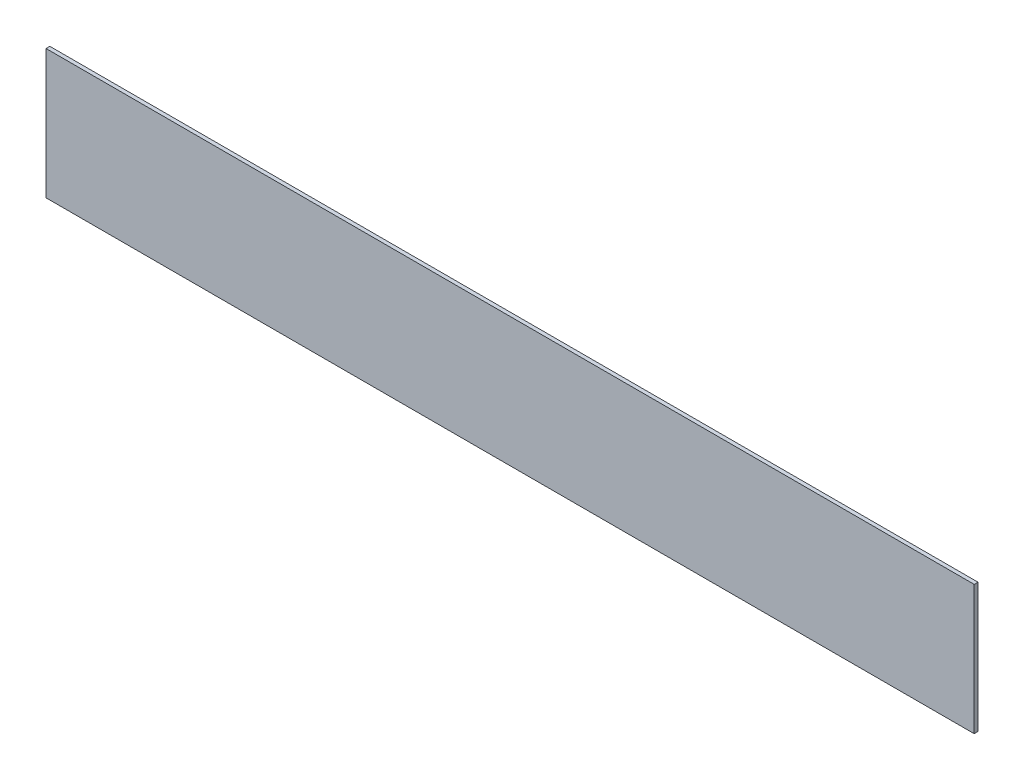
from build123d import *

# Parameters (mm, degrees)
SKETCH1_W           = 122
SKETCH1_H           = 17
BOSS_EXTRUDE1_DEPTH = 0.5


with BuildPart() as part:
    # Sketch1 → Boss-Extrude1 (new body)
    with BuildSketch(Plane.XY):
        Rectangle(SKETCH1_W, SKETCH1_H)
    extrude(amount=BOSS_EXTRUDE1_DEPTH)


solid = part.part
